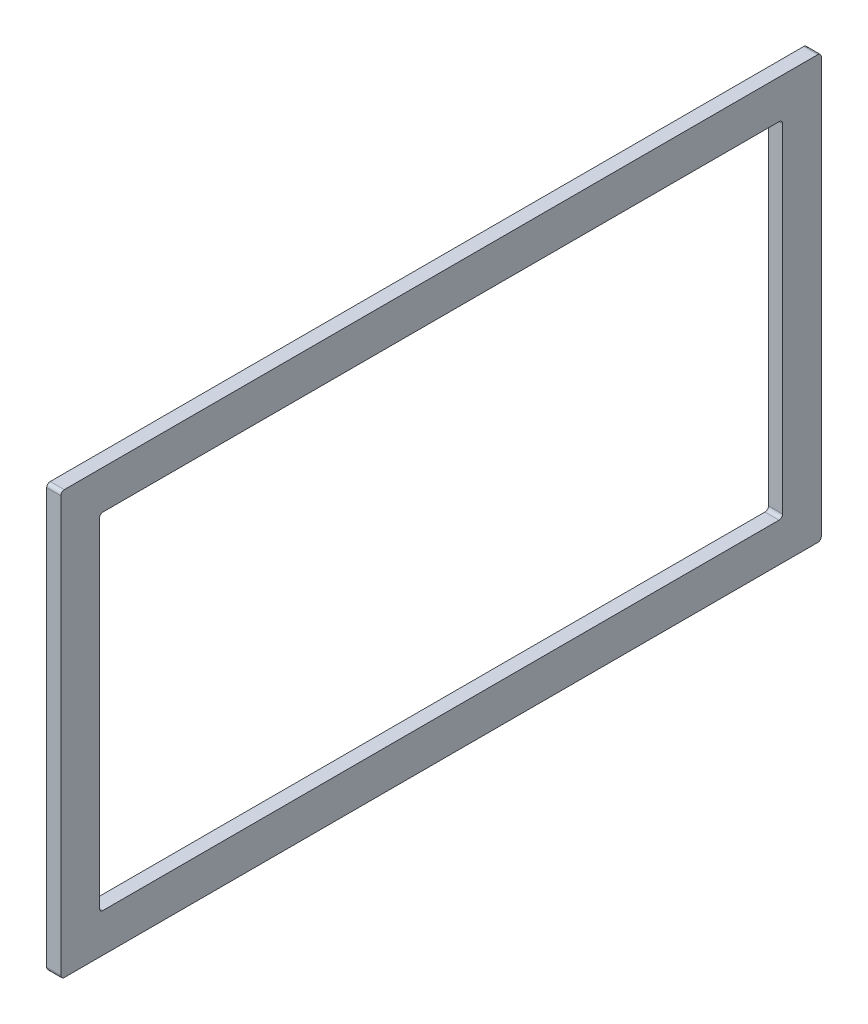
from build123d import *

# Parameters (mm, degrees)
SKETCH1_W           = 685.8
SKETCH1_H           = 381
SKETCH1_W_2         = 615.95
SKETCH1_H_2         = 311.15
BOSS_EXTRUDE1_DEPTH = 12.7
FILLET1_R           = 3.175


with BuildPart() as part:
    # Sketch1 → Boss-Extrude1 (new body)
    with BuildSketch(Plane.ZY.offset(311.15)):
        with Locations((0, 330.2)):
            Rectangle(SKETCH1_W, SKETCH1_H)
        with Locations((0, 330.2)):
            Rectangle(SKETCH1_W_2, SKETCH1_H_2, mode=Mode.SUBTRACT)
    extrude(amount=BOSS_EXTRUDE1_DEPTH)

    # Fillet1
    fillet1_edges = [part.edges().sort_by_distance(p)[0] for p in [
        (-317.5, 485.775, -307.975),
        (-317.5, 174.625, -307.975),
        (-317.5, 174.625, 307.975),
        (-317.5, 485.775, 307.975),
        (-317.5, 520.7, -342.9),
        (-317.5, 520.7, 342.9),
        (-317.5, 139.7, 342.9),
        (-317.5, 139.7, -342.9),
    ]]
    fillet(fillet1_edges, radius=FILLET1_R)


solid = part.part
